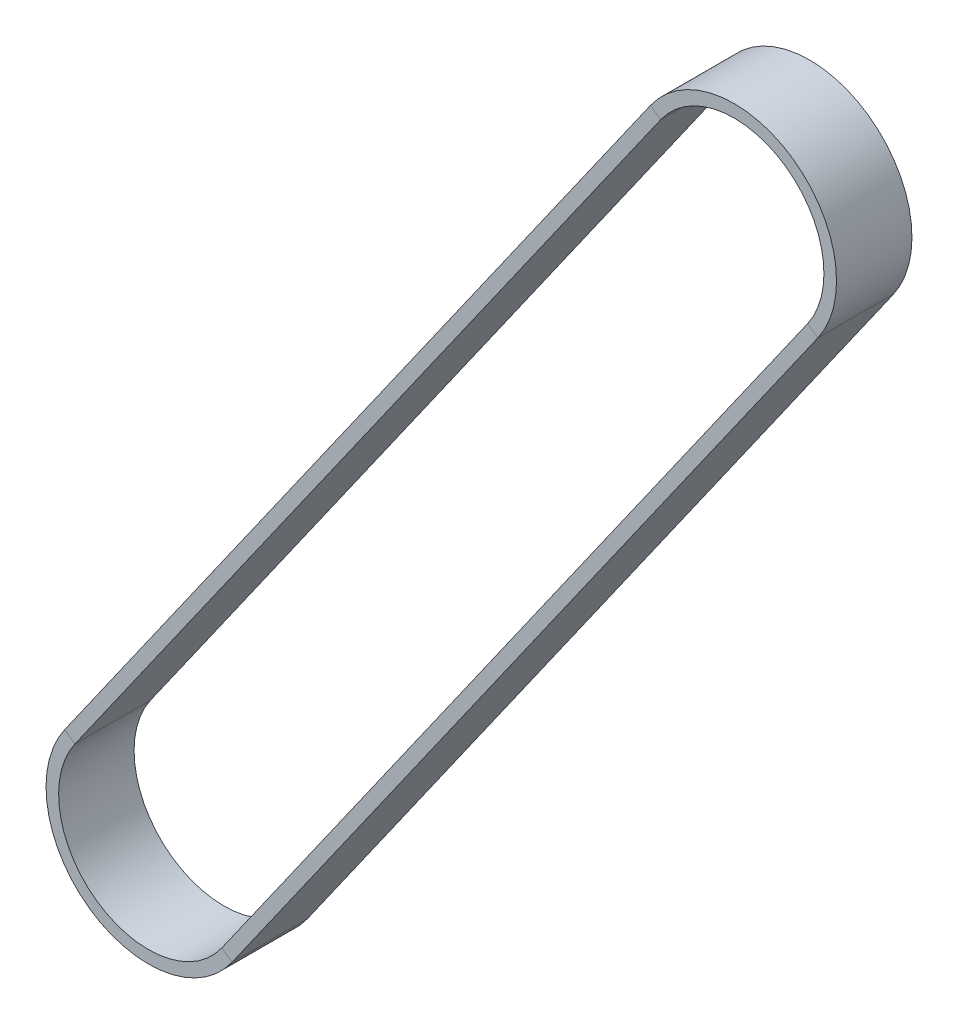
from build123d import *

# Parameters (mm, degrees)
SKETCH2_W = 1.5
SKETCH2_H = 9


with BuildPart() as part:
    # Sweep1: sweep along a path in Sketch1
    with BuildLine(Plane.XY) as sweep1_path:
        Line((6.319054119, 1.762345914), (-63.556322052, -97.660180283))
        ThreePointArc((-63.556322052, -97.660180283), (-79.51547051, -100.445491543), (-82.30078177, -84.486343085))
        Line((-82.30078177, -84.486343085), (-12.425405599, 14.936183112))
        ThreePointArc((-12.425405599, 14.936183112), (3.533742859, 17.721494372), (6.319054119, 1.762345914))
    # Sketch2 → Sweep1 (sweep)
    with BuildSketch(Plane(origin=(-12.425405599, 14.936183112, 0), x_dir=(0.818149507, -0.575005552, 0), z_dir=(0.575005552, 0.818149507, 0))):
        Rectangle(SKETCH2_W, SKETCH2_H)
    sweep(path=sweep1_path.line)


solid = part.part
